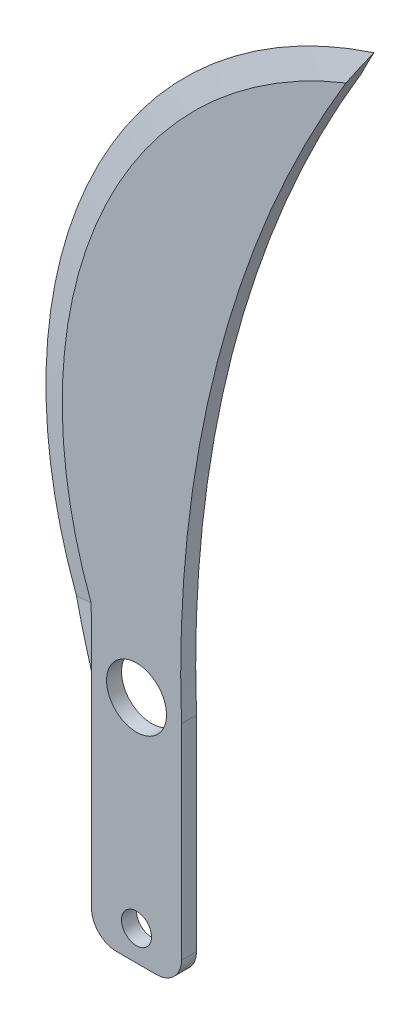
from build123d import *

# Parameters (mm, degrees)
SKETCH_1_R      = 3
SKETCH_1_R_2    = 6
EXTRUDE_1_DEPTH = 3
FILLET_1_R      = 5


with BuildPart() as part:
    # 草图1 → 凸台-拉伸1 (new body)
    with BuildSketch(Plane.XY):
        with BuildLine():
            Line((0, 0), (0, -46))
            Line((0, -46), (18, -46))
            Line((18, -46), (18, 0))
            ThreePointArc((18, 0), (26.133778881, 69.862314787), (55, 134))
            ThreePointArc((55, 134), (-3.509871984, 79.727932531), (0, 0))
        make_face()
        with Locations((9, -40)):
            Circle(SKETCH_1_R, mode=Mode.SUBTRACT)
        with Locations((9, 0)):
            Circle(SKETCH_1_R_2, mode=Mode.SUBTRACT)
    extrude(amount=EXTRUDE_1_DEPTH)

    # 圆角1
    fillet_1_edges = [part.edges().sort_by_distance(p)[0] for p in [
        (18, -46, 1.5),
        (0, -46, 1.5),
    ]]
    fillet(fillet_1_edges, radius=FILLET_1_R)

    # 切除-扫描5: sweep along a path in 草图14
    with BuildLine(Plane.XY.offset(1.5)) as sweep_5_path:
        ThreePointArc((55, 134), (-1.251298398, 84.80293124), (-4.517936931, 10.144447336))
    # 草图13 → 切除-扫描5 (sweep, cut)
    with BuildSketch(Plane(origin=(89.145258508, 28.985369875, 0), x_dir=(0, 0, 1), z_dir=(-0.9509927898455951, -0.30921305545156413, 0))):
        Polygon((1.5, 110.426315789), (-0.806867017, 103.109868349), (-0.806867017, 111.673722013), (3.806867017, 111.673722013), (3.806867017, 103.109868349), align=None)
    sweep(path=sweep_5_path.line, mode=Mode.SUBTRACT)

    # 切除-扫描6: sweep along a path in 草图16
    with BuildLine(Plane.XY.offset(1.5)) as sweep_6_path:
        Line((-0.066361056, 11.822616816), (0, 0))
    # 草图15 → 切除-扫描6 (sweep, cut)
    with BuildSketch(Plane(origin=(-3.910599214, 10.373403475, 0), x_dir=(0.9357176547303454, 0.3527498697745219, 0), z_dir=(-0.3527498697745219, 0.9357176547303454, 0))):
        Polygon((-2.121804917, 0.787609901), (-2.121804917, -3), (-2.121804917, -3.6210581), (6.078075974, -3.6210581), (-0.649060873, -1.5), (6.606310798, 0.787609901), align=None)
    sweep(path=sweep_6_path.line, mode=Mode.SUBTRACT)


solid = part.part
